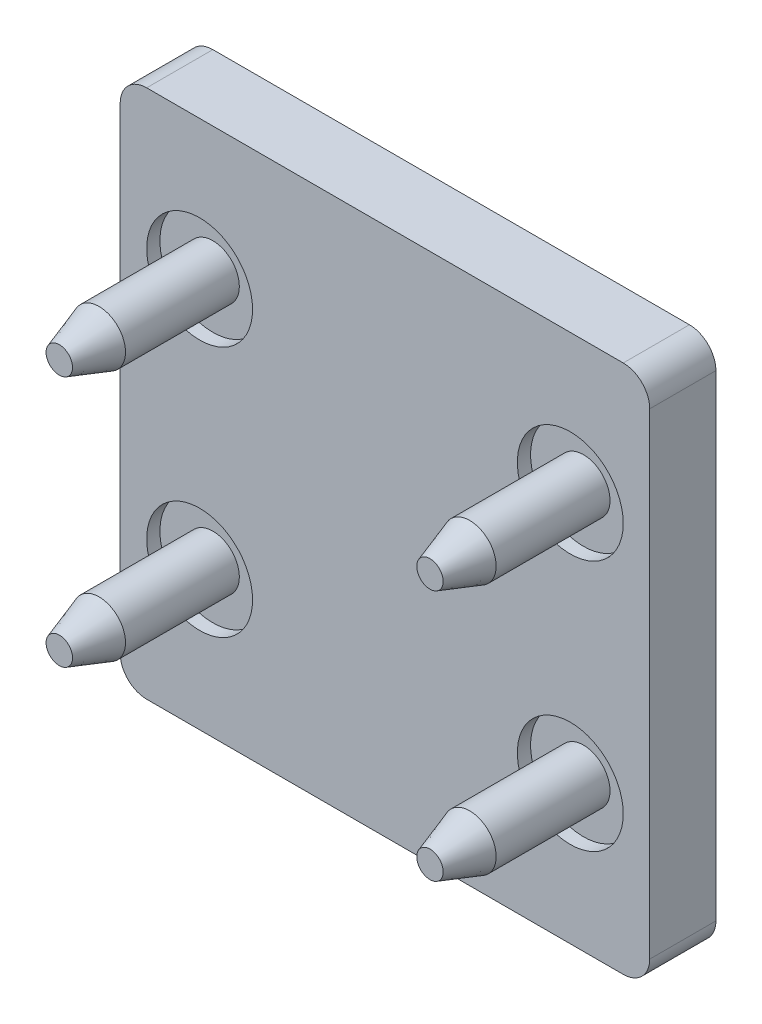
from build123d import *

# Parameters (mm, degrees)
BOSS_EXTRUDE1_DEPTH = 2.5
SKETCH2_W           = 0.5
SKETCH2_H           = 2
SKETCH3_W           = 0.5
SKETCH3_H           = 2
SKETCH4_W           = 0.5
SKETCH4_H           = 2
SKETCH5_W           = 0.5
SKETCH5_H           = 2


with BuildPart() as part:
    # Sketch1 → Boss-Extrude1 (new body)
    with BuildSketch(Plane.XY):
        with BuildLine():
            Line((-10, 9), (-10, -9))
            ThreePointArc((-10, -9), (-9.707106781, -9.707106781), (-9, -10))
            Line((-9, -10), (9, -10))
            ThreePointArc((9, -10), (9.707106781, -9.707106781), (10, -9))
            Line((10, -9), (10, 9))
            ThreePointArc((10, 9), (9.707106781, 9.707106781), (9, 10))
            Line((9, 10), (-9, 10))
            ThreePointArc((-9, 10), (-9.707106781, 9.707106781), (-10, 9))
        make_face()
    extrude(amount=-BOSS_EXTRUDE1_DEPTH)

    # Sketch2 → Cut-Revolve1 (revolve, cut)
    with BuildSketch(Plane(origin=(-7, 0, 0), x_dir=(0, 0, -1), z_dir=(1, 0, 0))):
        with Locations((0.25, 5.75)):
            Rectangle(SKETCH2_W, SKETCH2_H)
    revolve(axis=Axis((-7, 4.75, -0.5), (0, 0, 1)), mode=Mode.SUBTRACT)

    # Sketch3 → Cut-Revolve2 (revolve, cut)
    with BuildSketch(Plane(origin=(7, 0, 0), x_dir=(0, 0, -1), z_dir=(1, 0, 0))):
        with Locations((0.25, 5.75)):
            Rectangle(SKETCH3_W, SKETCH3_H)
    revolve(axis=Axis((7, 4.75, -0.5), (0, 0, 1)), mode=Mode.SUBTRACT)

    # Sketch4 → Cut-Revolve3 (revolve, cut)
    with BuildSketch(Plane(origin=(7, 0, 0), x_dir=(0, 0, -1), z_dir=(1, 0, 0))):
        with Locations((0.25, -3.75)):
            Rectangle(SKETCH4_W, SKETCH4_H)
    revolve(axis=Axis((7, -4.75, -0.5), (0, 0, 1)), mode=Mode.SUBTRACT)

    # Sketch5 → Cut-Revolve4 (revolve, cut)
    with BuildSketch(Plane(origin=(-7, 0, 0), x_dir=(0, 0, -1), z_dir=(1, 0, 0))):
        with Locations((0.25, -3.75)):
            Rectangle(SKETCH5_W, SKETCH5_H)
    revolve(axis=Axis((-7, -4.75, -0.5), (0, 0, 1)), mode=Mode.SUBTRACT)

    # Sketch6 → Revolve1 (revolve)
    with BuildSketch(Plane(origin=(-7, 0, 0), x_dir=(0, 0, -1), z_dir=(1, 0, 0))):
        Polygon((-5.3, 4.75), (-5.3, 5.25), (-3.8, 5.75), (0.5, 5.75), (0.5, 4.75), align=None)
    revolve(axis=Axis((-7, 4.75, -0.5), (0, 0, 1)))

    # Sketch7 → Revolve2 (revolve)
    with BuildSketch(Plane(origin=(7, 0, 0), x_dir=(0, 0, -1), z_dir=(1, 0, 0))):
        Polygon((-5.3, 4.75), (-5.3, 5.25), (-3.8, 5.75), (0.5, 5.75), (0.5, 4.75), align=None)
    revolve(axis=Axis((7, 4.75, -0.5), (0, 0, 1)))

    # Sketch8 → Revolve3 (revolve)
    with BuildSketch(Plane(origin=(7, 0, 0), x_dir=(0, 0, -1), z_dir=(1, 0, 0))):
        Polygon((-5.3, -4.75), (-5.3, -4.25), (-3.8, -3.75), (0.5, -3.75), (0.5, -4.75), align=None)
    revolve(axis=Axis((7, -4.75, -0.5), (0, 0, 1)))

    # Sketch9 → Revolve4 (revolve)
    with BuildSketch(Plane(origin=(-7, 0, 0), x_dir=(0, 0, -1), z_dir=(1, 0, 0))):
        Polygon((-5.3, -4.75), (-5.3, -4.25), (-3.8, -3.75), (0.5, -3.75), (0.5, -4.75), align=None)
    revolve(axis=Axis((-7, -4.75, -0.5), (0, 0, 1)))


solid = part.part
